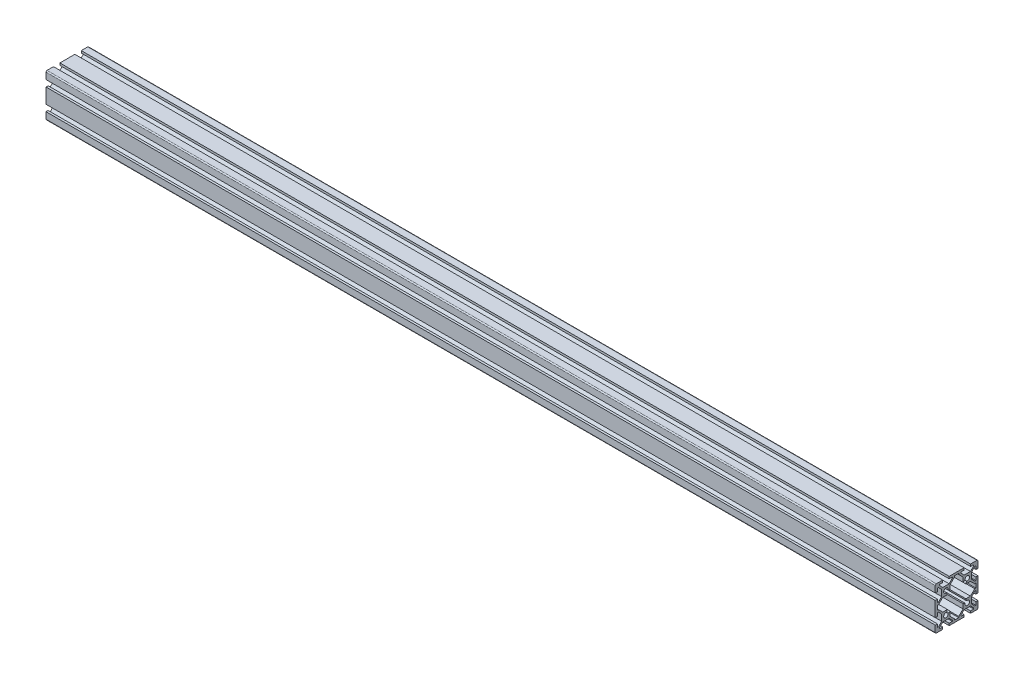
from build123d import *

# Parameters (mm, degrees)
BOSS_EXTRUDE1_DEPTH = 832


with BuildPart() as part:
    # Sketch1 → Boss-Extrude1 (new body)
    with BuildSketch(Plane(origin=(0, 0, 0), x_dir=(0, 0, -1), z_dir=(1, 0, 0))):
        with BuildLine():
            Line((-20, 19), (-20, 13))
            Line((-20, 13), (-18, 13))
            Line((-18, 13), (-18, 16))
            Line((-18, 16), (-17.060660172, 16))
            Line((-17.060660172, 16), (-14, 12.939339828))
            Line((-14, 12.939339828), (-14, 7.060660172))
            Line((-14, 7.060660172), (-17.060660172, 4))
            Line((-17.060660172, 4), (-18, 4))
            Line((-18, 4), (-18, 7))
            Line((-18, 7), (-20, 7))
            Line((-20, 7), (-20, -7))
            Line((-20, -7), (-18, -7))
            Line((-18, -7), (-18, -4))
            Line((-18, -4), (-17.060660172, -4))
            Line((-17.060660172, -4), (-14, -7.060660172))
            Line((-14, -7.060660172), (-14, -12.939339828))
            Line((-14, -12.939339828), (-17.060660172, -16))
            Line((-17.060660172, -16), (-18, -16))
            Line((-18, -16), (-18, -13))
            Line((-18, -13), (-20, -13))
            Line((-20, -13), (-20, -19))
            ThreePointArc((-20, -19), (-19.707106781, -19.707106781), (-19, -20))
            Line((-19, -20), (-13, -20))
            Line((-13, -20), (-13, -18))
            Line((-13, -18), (-16, -18))
            Line((-16, -18), (-16, -17.060660172))
            Line((-16, -17.060660172), (-12.939339828, -14))
            Line((-12.939339828, -14), (-7.060660172, -14))
            Line((-7.060660172, -14), (-4, -17.060660172))
            Line((-4, -17.060660172), (-4, -18))
            Line((-4, -18), (-7, -18))
            Line((-7, -18), (-7, -20))
            Line((-7, -20), (7, -20))
            Line((7, -20), (7, -18))
            Line((7, -18), (4, -18))
            Line((4, -18), (4, -17.060660172))
            Line((4, -17.060660172), (7.060660172, -14))
            Line((7.060660172, -14), (12.939339828, -14))
            Line((12.939339828, -14), (16, -17.060660172))
            Line((16, -17.060660172), (16, -18))
            Line((16, -18), (13, -18))
            Line((13, -18), (13, -20))
            Line((13, -20), (19, -20))
            ThreePointArc((19, -20), (19.707106781, -19.707106781), (20, -19))
            Line((20, -19), (20, -13))
            Line((20, -13), (18, -13))
            Line((18, -13), (18, -16))
            Line((18, -16), (17.060660172, -16))
            Line((17.060660172, -16), (14, -12.939339828))
            Line((14, -12.939339828), (14, -7.060660172))
            Line((14, -7.060660172), (17.060660172, -4))
            Line((17.060660172, -4), (18, -4))
            Line((18, -4), (18, -7))
            Line((18, -7), (20, -7))
            Line((20, -7), (20, 7))
            Line((20, 7), (18, 7))
            Line((18, 7), (18, 4))
            Line((18, 4), (17.060660172, 4))
            Line((17.060660172, 4), (14, 7.060660172))
            Line((14, 7.060660172), (14, 12.939339828))
            Line((14, 12.939339828), (17.060660172, 16))
            Line((17.060660172, 16), (18, 16))
            Line((18, 16), (18, 13))
            Line((18, 13), (20, 13))
            Line((20, 13), (20, 19))
            ThreePointArc((20, 19), (19.707106781, 19.707106781), (19, 20))
            Line((19, 20), (13, 20))
            Line((13, 20), (13, 18))
            Line((13, 18), (16, 18))
            Line((16, 18), (16, 17.060660172))
            Line((16, 17.060660172), (12.939339828, 14))
            Line((12.939339828, 14), (7.060660172, 14))
            Line((7.060660172, 14), (4, 17.060660172))
            Line((4, 17.060660172), (4, 18))
            Line((4, 18), (7, 18))
            Line((7, 18), (7, 20))
            Line((7, 20), (-7, 20))
            Line((-7, 20), (-7, 18))
            Line((-7, 18), (-4, 18))
            Line((-4, 18), (-4, 17.060660172))
            Line((-4, 17.060660172), (-7.060660172, 14))
            Line((-7.060660172, 14), (-12.939339828, 14))
            Line((-12.939339828, 14), (-16, 17.060660172))
            Line((-16, 17.060660172), (-16, 18))
            Line((-16, 18), (-13, 18))
            Line((-13, 18), (-13, 20))
            Line((-13, 20), (-19, 20))
            ThreePointArc((-19, 20), (-19.707106781, 19.707106781), (-20, 19))
        make_face()
        with BuildLine():
            Line((-16.939339828, 2), (-18, 2))
            Line((-18, 2), (-18, -2))
            Line((-18, -2), (-16.939339828, -2))
            Line((-16.939339828, -2), (-12.939339828, -6))
            Line((-12.939339828, -6), (-8.666662697, -6))
            Line((-8.666662697, -6), (-9.335919912, -8.007765667))
            ThreePointArc((-9.335919912, -8.007765667), (-11.48492424, -11.48492424), (-8.007765667, -9.335919912))
            Line((-8.007765667, -9.335919912), (-6, -8.666662697))
            Line((-6, -8.666662697), (-6, -12.939339828))
            Line((-6, -12.939339828), (-2, -16.939339828))
            Line((-2, -16.939339828), (-2, -18))
            Line((-2, -18), (2, -18))
            Line((2, -18), (2, -16.939339828))
            Line((2, -16.939339828), (6, -12.939339828))
            Line((6, -12.939339828), (6, -8.666662697))
            Line((6, -8.666662697), (8.007765667, -9.335919912))
            ThreePointArc((8.007765667, -9.335919912), (11.48492424, -11.48492424), (9.335919912, -8.007765667))
            Line((9.335919912, -8.007765667), (8.666662697, -6))
            Line((8.666662697, -6), (12.939339828, -6))
            Line((12.939339828, -6), (16.939339828, -2))
            Line((16.939339828, -2), (18, -2))
            Line((18, -2), (18, 2))
            Line((18, 2), (16.939339828, 2))
            Line((16.939339828, 2), (12.939339828, 6))
            Line((12.939339828, 6), (8.666662697, 6))
            Line((8.666662697, 6), (9.335919912, 8.007765667))
            ThreePointArc((9.335919912, 8.007765667), (11.48492424, 11.48492424), (8.007765667, 9.335919912))
            Line((8.007765667, 9.335919912), (6, 8.666662697))
            Line((6, 8.666662697), (6, 12.939339828))
            Line((6, 12.939339828), (2, 16.939339828))
            Line((2, 16.939339828), (2, 18))
            Line((2, 18), (-2, 18))
            Line((-2, 18), (-2, 16.939339828))
            Line((-2, 16.939339828), (-6, 12.939339828))
            Line((-6, 12.939339828), (-6, 8.666662697))
            Line((-6, 8.666662697), (-8.007765667, 9.335919912))
            ThreePointArc((-8.007765667, 9.335919912), (-11.48492424, 11.48492424), (-9.335919912, 8.007765667))
            Line((-9.335919912, 8.007765667), (-8.666662697, 6))
            Line((-8.666662697, 6), (-12.939339828, 6))
            Line((-12.939339828, 6), (-16.939339828, 2))
        make_face(mode=Mode.SUBTRACT)
    extrude(amount=BOSS_EXTRUDE1_DEPTH)


solid = part.part
